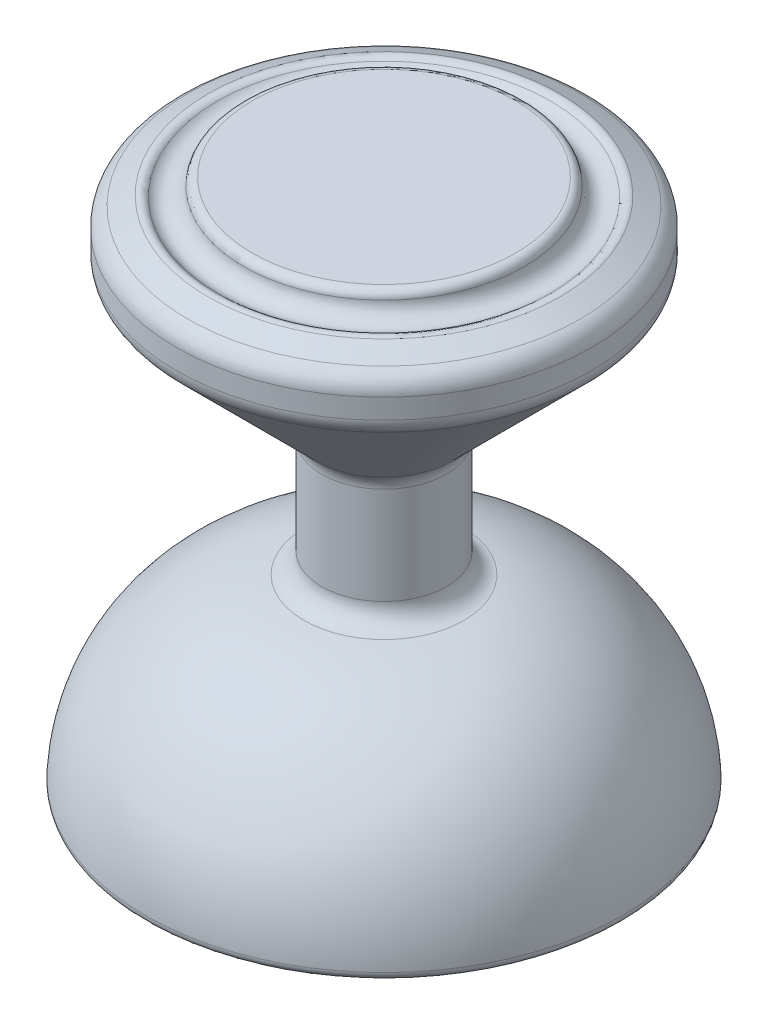
from build123d import *

# Parameters (mm, degrees)
SKETCH_2_W          = 2.1
SKETCH_2_H          = 1.2
CUT_EXTRUDE_1_DEPTH = 3.8
FILLET_1_R          = 0.4
FILLET_2_R          = 1
FILLET_3_R          = 0.2


with BuildPart() as part:
    # 草图1 → 旋转1 (revolve)
    with BuildSketch(Plane.XY):
        with BuildLine():
            Line((0, 25.5), (0, 7.619634081))
            Line((0, 7.619634081), (0, 6))
            Line((0, 6), (7.79900378, 6))
            ThreePointArc((7.79900378, 6), (9.793622602, 3.289961268), (10.5, 0))
            Line((10.5, 0), (11.5, 0))
            ThreePointArc((11.5, 0), (9.03910386, 6.189709202), (3, 9))
            Line((3, 9), (3, 15))
            Line((3, 15), (10, 22))
            Line((10, 22), (10, 24))
            ThreePointArc((10, 24), (9.09383514, 24.442846169), (8.181104002, 24.871995736))
            ThreePointArc((8.181104002, 24.871995736), (7.185997868, 24.504893866), (6.818895998, 25.5))
            Line((6.818895998, 25.5), (0, 25.5))
        make_face()
    revolve(axis=Axis((0, 0, 0), (0, 1, 0)))

    # 草图2 → 切除-拉伸1 (cut)
    with BuildSketch(Plane.XZ.offset(-6)):
        Rectangle(SKETCH_2_W, SKETCH_2_H)
    extrude(amount=-CUT_EXTRUDE_1_DEPTH, mode=Mode.SUBTRACT)

    # 圆角1
    fillet_1_edges = [part.edges().sort_by_distance(p)[0] for p in [
        (-11.5, 0, 0),
        (-8.181104002, 24.871995736, 0),
        (-6.818895998, 25.5, 0),
        (-10.5, 0, 0),
        (-7.79900378, 6, 0),
    ]]
    fillet(fillet_1_edges, radius=FILLET_1_R)

    # 圆角2
    fillet_2_edges = [part.edges().sort_by_distance(p)[0] for p in [
        (-10, 22, 0),
        (-10, 24, 0),
        (-3, 9, 0),
        (-3, 15, 0),
    ]]
    fillet(fillet_2_edges, radius=FILLET_2_R)

    # 圆角3
    fillet_3_edges = [part.edges().sort_by_distance(p)[0] for p in [
        (-1.05, 6, 0),
        (0, 6, -0.6),
        (0, 6, 0.6),
        (1.05, 6, 0),
    ]]
    fillet(fillet_3_edges, radius=FILLET_3_R)


solid = part.part
